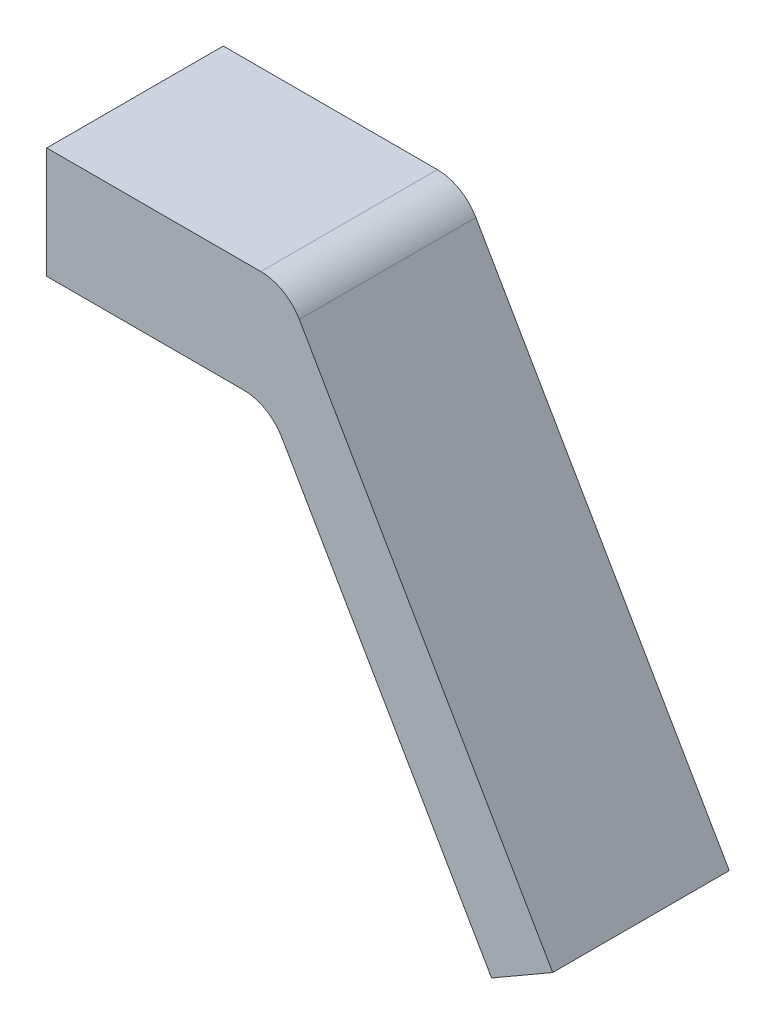
from build123d import *

# Parameters (mm, degrees)
BOSS_EXTRUDE1_DEPTH = 15.875
FILLET1_R           = 4


with BuildPart() as part:
    # Sketch1 → Boss-Extrude1 (new body)
    with BuildSketch(Plane.XY):
        Polygon((-10, 0), (10, 0), (30, -34.641016151), (35.499261314, -31.466016151), (11.558845727, 10), (-10, 10), align=None)
    extrude(amount=BOSS_EXTRUDE1_DEPTH)

    # Fillet1
    fillet1_edges = [part.edges().sort_by_distance(p)[0] for p in [
        (11.558845727, 10, 7.9375),
        (10, 0, 7.9375),
    ]]
    fillet(fillet1_edges, radius=FILLET1_R)


solid = part.part
